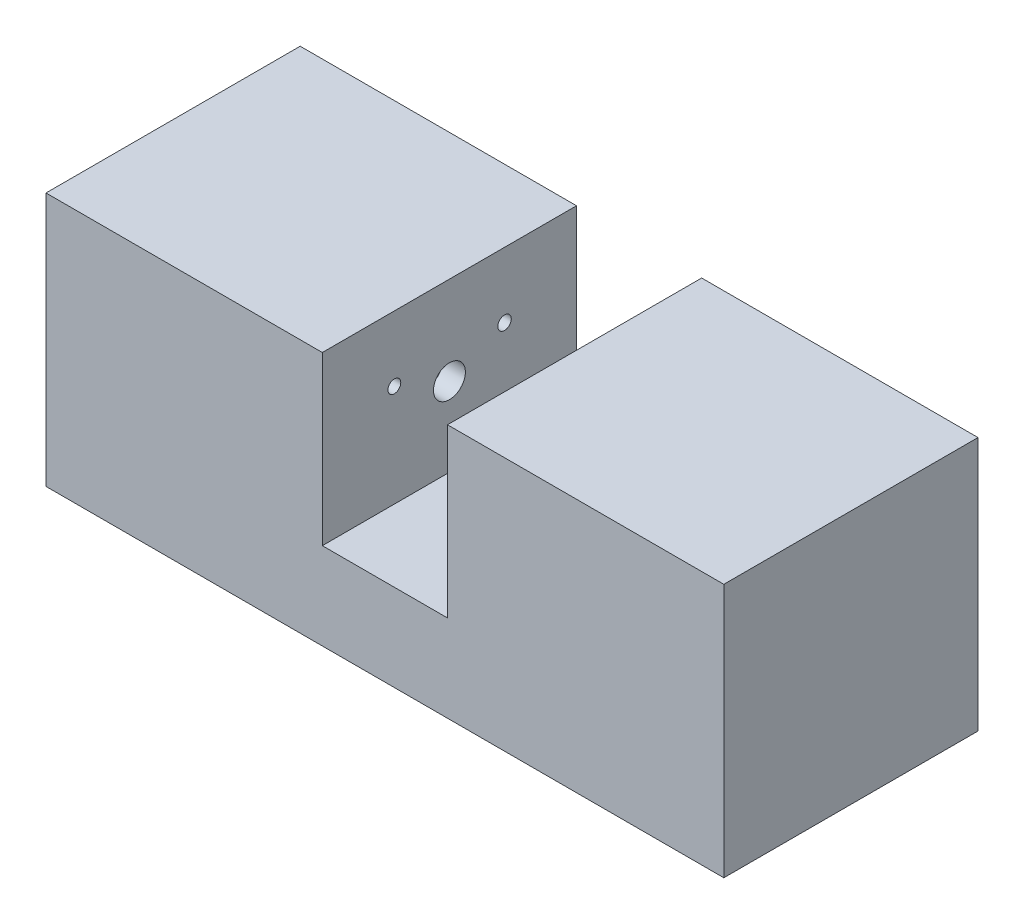
from build123d import *

# Parameters (mm, degrees)
SKICA1_W                 = 30
SKICA1_H                 = 30
P_IDAT_VYSUNUT_M1_DEPTH  = 40
SKICA2_W                 = 14.772421132
SKICA2_H                 = 61.833184582
ODEBRAT_VYSUNUT_M1_DEPTH = 180
SKICA3_W                 = 22.785077148
SKICA3_H                 = 25.847285536
ODEBRAT_VYSUNUT_M2_DEPTH = 30
SKICA4_R                 = 0.794930896
SKICA4_R_2               = 0.758797673
SKICA4_R_3               = 1.053455412
SKICA4_R_4               = 0.975597008
ODEBRAT_VYSUNUT_M3_DEPTH = 60
SKICA5_R                 = 1.886179275
ODEBRAT_VYSUNUT_M4_DEPTH = 30
SKICA6_R                 = 5
SKICA6_R_2               = 4
P_IDAT_VYSUNUT_M2_DEPTH  = 5


with BuildPart() as part:
    # Skica1 → Přidat vysunutím1 (new body, symmetric)
    with BuildSketch(Plane(origin=(0, 0, 0), x_dir=(0, 0, -1), z_dir=(1, 0, 0))):
        Rectangle(SKICA1_W, SKICA1_H)
    extrude(amount=P_IDAT_VYSUNUT_M1_DEPTH, both=True)

    # Skica2 → Odebrat vysunutím1 (cut)
    with BuildSketch(Plane(origin=(0, 0, -15), x_dir=(-1, 0, 0), z_dir=(0, 0, -1))):
        with Locations((0, 26.170702713)):
            Rectangle(SKICA2_W, SKICA2_H)
    extrude(amount=-ODEBRAT_VYSUNUT_M1_DEPTH, mode=Mode.SUBTRACT)

    # Skica3 → Odebrat vysunutím2 (cut)
    with BuildSketch(Plane.ZY.offset(40)):
        Rectangle(SKICA3_W, SKICA3_H)
    extrude(amount=-ODEBRAT_VYSUNUT_M2_DEPTH, mode=Mode.SUBTRACT)

    # Skica4 → Odebrat vysunutím3 (cut)
    with BuildSketch(Plane(origin=(-7.386210566, 0, 0), x_dir=(0, 0, -1), z_dir=(1, 0, 0))):
        with Locations((6.506049624, 7.292174822)):
            Circle(SKICA4_R)
        with Locations((-6.501910486, 7.292174822)):
            Circle(SKICA4_R_2)
        with Locations((-6.285111151, -9.654306544)):
            Circle(SKICA4_R_3)
        with Locations((6.506049624, -9.87110588)):
            Circle(SKICA4_R_4)
    extrude(amount=-ODEBRAT_VYSUNUT_M3_DEPTH, mode=Mode.SUBTRACT)

    # Skica5 → Odebrat vysunutím4 (cut)
    with BuildSketch(Plane.ZY.offset(10)):
        with Locations((0, 4.56487451)):
            Circle(SKICA5_R)
    extrude(amount=-ODEBRAT_VYSUNUT_M4_DEPTH, mode=Mode.SUBTRACT)

    # Skica6 → Přidat vysunutím2 (add)
    with BuildSketch(Plane(origin=(0, 0, -15), x_dir=(-1, 0, 0), z_dir=(0, 0, -1))):
        with Locations((-30, 3)):
            Circle(SKICA6_R)
        with Locations((-30, 3)):
            Circle(SKICA6_R_2, mode=Mode.SUBTRACT)
    p_idat_vysunut_m2 = extrude(amount=P_IDAT_VYSUNUT_M2_DEPTH)

    # Zrcadlit1: Přidat vysunutím2 across plane
    add(p_idat_vysunut_m2.mirror(Plane(origin=(0, 0, 0), x_dir=(0, 0, 1), z_dir=(1, 0, 0))))


solid = part.part
